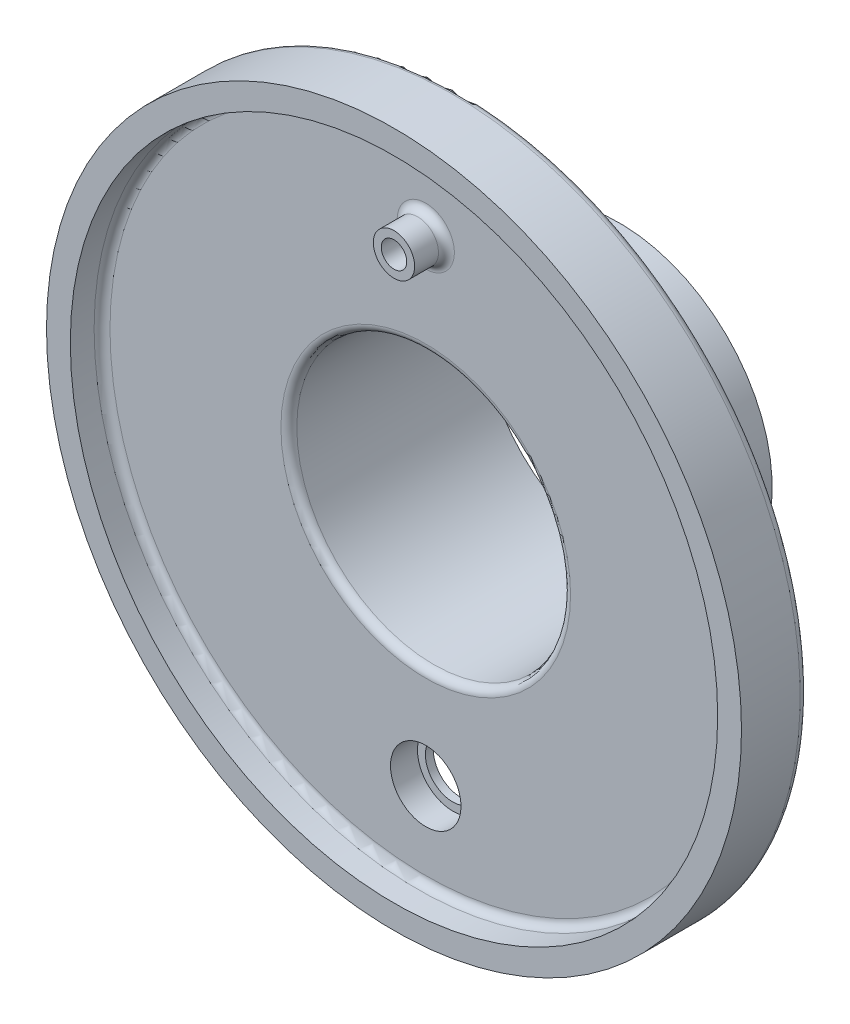
from build123d import *

# Parameters (mm, degrees)
SKETCH1_R           = 111.2139
SKETCH1_R_2         = 103.5939
BOSS_EXTRUDE1_DEPTH = 10.16
SKETCH2_R           = 111.2139
SKETCH2_R_2         = 43.815
BOSS_EXTRUDE3_DEPTH = 11.176
SKETCH3_R           = 48.895
SKETCH3_R_2         = 43.815
BOSS_EXTRUDE4_DEPTH = 50.8
FILLET1_R           = 2.54
FILLET2_R           = 2.54
SKETCH4_R           = 11.2776
CUT_EXTRUDE1_DEPTH  = 50.8
SKETCH5_R           = 6.6167
SKETCH5_R_2         = 4.0767
BOSS_EXTRUDE5_DEPTH = 10.16
FILLET3_R           = 2.54
SKETCH6_R           = 11.2776
SKETCH6_R_2         = 8.7376
BOSS_EXTRUDE6_DEPTH = 2.54


with BuildPart() as part:
    # Sketch1 → Boss-Extrude1 (new body)
    with BuildSketch(Plane.XY):
        Circle(SKETCH1_R)
        Circle(SKETCH1_R_2, mode=Mode.SUBTRACT)
    extrude(amount=BOSS_EXTRUDE1_DEPTH)

    # Sketch2 → Boss-Extrude3 (add)
    with BuildSketch(Plane(origin=(0, 0, 0), x_dir=(-1, 0, 0), z_dir=(0, 0, -1))):
        Circle(SKETCH2_R)
        Circle(SKETCH2_R_2, mode=Mode.SUBTRACT)
    extrude(amount=BOSS_EXTRUDE3_DEPTH)

    # Sketch3 → Boss-Extrude4 (add)
    with BuildSketch(Plane(origin=(0, 0, -11.176), x_dir=(-1, 0, 0), z_dir=(0, 0, -1))):
        Circle(SKETCH3_R)
        Circle(SKETCH3_R_2, mode=Mode.SUBTRACT)
    extrude(amount=BOSS_EXTRUDE4_DEPTH)

    # Fillet1
    fillet1_edges = [part.edges().sort_by_distance(p)[0] for p in [
        (-103.5939, 0, 0),
    ]]
    fillet(fillet1_edges, radius=FILLET1_R)

    # Fillet2
    fillet2_edges = [part.edges().sort_by_distance(p)[0] for p in [
        (48.895, 0, -11.176),
        (43.815, 0, 0),
        (111.2139, 0, -11.176),
    ]]
    fillet(fillet2_edges, radius=FILLET2_R)

    # Sketch4 → Cut-Extrude1 (cut)
    with BuildSketch(Plane(origin=(0, 0, -11.176), x_dir=(-1, 0, 0), z_dir=(0, 0, -1))):
        with Locations((0, -76.2)):
            Circle(SKETCH4_R)
    extrude(amount=-CUT_EXTRUDE1_DEPTH, mode=Mode.SUBTRACT)

    # Sketch5 → Boss-Extrude5 (add)
    with BuildSketch(Plane.XY):
        with Locations((0, 76.2)):
            Circle(SKETCH5_R)
        with Locations((0, 76.2)):
            Circle(SKETCH5_R_2, mode=Mode.SUBTRACT)
    extrude(amount=BOSS_EXTRUDE5_DEPTH)

    # Fillet3
    fillet3_edges = [part.edges().sort_by_distance(p)[0] for p in [
        (-6.6167, 76.2, 0),
    ]]
    fillet(fillet3_edges, radius=FILLET3_R)

    # Sketch6 → Boss-Extrude6 (add)
    with BuildSketch(Plane(origin=(0, 0, -11.176), x_dir=(-1, 0, 0), z_dir=(0, 0, -1))):
        with Locations((0, -76.2)):
            Circle(SKETCH6_R)
        with Locations((0, -76.2)):
            Circle(SKETCH6_R_2, mode=Mode.SUBTRACT)
    extrude(amount=-BOSS_EXTRUDE6_DEPTH)


solid = part.part
